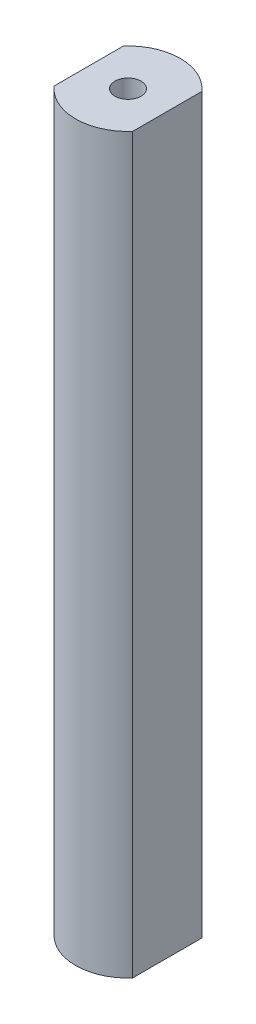
from build123d import *

# Parameters (mm, degrees)
SKETCH1_R           = 6.35
SKETCH1_R_2         = 1.5875
BOSS_EXTRUDE1_DEPTH = 88.9
CUT_EXTRUDE1_DEPTH  = 89.9


with BuildPart() as part:
    # Sketch1 → Boss-Extrude1 (new body)
    with BuildSketch(Plane(origin=(0, 0, 0), x_dir=(1, 0, 0), z_dir=(0, 1, 0))):
        Circle(SKETCH1_R)
        Circle(SKETCH1_R_2, mode=Mode.SUBTRACT)
    extrude(amount=BOSS_EXTRUDE1_DEPTH)

    # Sketch2 → Cut-Extrude1 (cut, through all)
    with BuildSketch(Plane(origin=(0, 88.9, 0), x_dir=(1, 0, 0), z_dir=(0, 1, 0))):
        with BuildLine():
            ThreePointArc((-4.7625, 4.200130206), (-6.35, 0), (-4.7625, -4.200130206))
            Line((-4.7625, -4.200130206), (-4.7625, 4.200130206))
        make_face()
        with BuildLine():
            Line((4.7625, 4.200130206), (4.7625, -4.200130206))
            ThreePointArc((4.7625, -4.200130206), (5.939881102, -2.24506403), (6.35, 0))
            ThreePointArc((6.35, 0), (5.939881102, 2.24506403), (4.7625, 4.200130206))
        make_face()
    extrude(amount=-CUT_EXTRUDE1_DEPTH, mode=Mode.SUBTRACT)


solid = part.part
